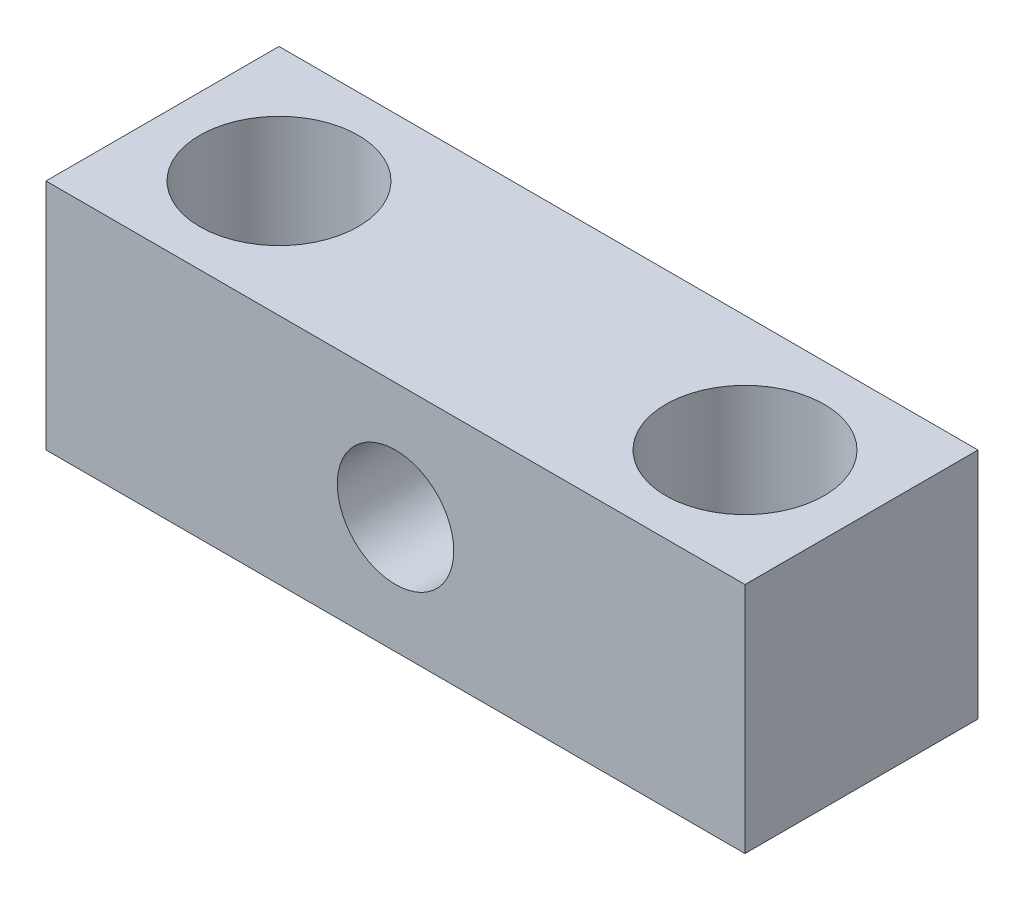
from build123d import *

# Parameters (mm, degrees)
CROQUIS1_W              = 15
CROQUIS1_H              = 5
SALIENTE_EXTRUIR1_DEPTH = 5
CROQUIS2_R              = 1.7
CORTAR_EXTRUIR1_DEPTH   = 6
CROQUIS3_R              = 1.25
CORTAR_EXTRUIR2_DEPTH   = 6


with BuildPart() as part:
    # Croquis1 → Saliente-Extruir1 (new body)
    with BuildSketch(Plane(origin=(0, 0, 0), x_dir=(1, 0, 0), z_dir=(0, 1, 0))):
        Rectangle(CROQUIS1_W, CROQUIS1_H)
    extrude(amount=SALIENTE_EXTRUIR1_DEPTH)

    # Croquis2 → Cortar-Extruir1 (cut, through all)
    with BuildSketch(Plane(origin=(0, 5, 0), x_dir=(1, 0, 0), z_dir=(0, 1, 0))):
        with Locations((-5, 0)):
            Circle(CROQUIS2_R)
        with Locations((5, 0)):
            Circle(CROQUIS2_R)
    extrude(amount=-CORTAR_EXTRUIR1_DEPTH, mode=Mode.SUBTRACT)

    # Croquis3 → Cortar-Extruir2 (cut, through all)
    with BuildSketch(Plane.XY.offset(2.5)):
        with Locations((0, 2.5)):
            Circle(CROQUIS3_R)
    extrude(amount=-CORTAR_EXTRUIR2_DEPTH, mode=Mode.SUBTRACT)


solid = part.part
